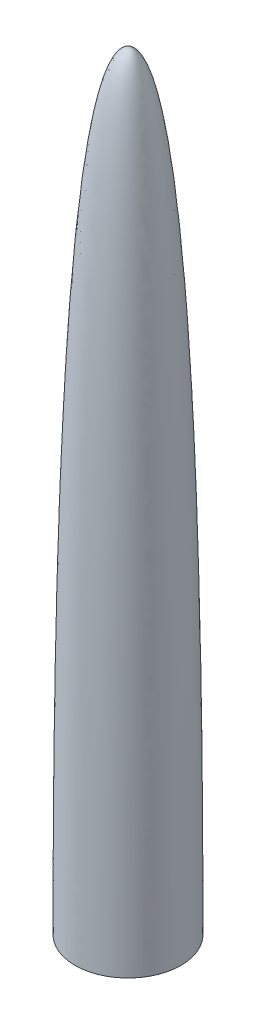
from build123d import *


with BuildPart() as part:
    # Sketch1 → Revolve1 (revolve)
    with BuildSketch(Plane.XY):
        with BuildLine():
            Line((0, 409.654213515), (0, 412.75))
            add(Edge.make_bspline(
                [(0, 412.75), (25.4, 412.75), (28.4988, 152.4), (28.4988, 0)],
                knots=[0, 0, 0, 0, 1, 1, 1, 1], degree=3))
            Line((28.4988, 0), (26.492020388, 0))
            Line((26.492020388, 0), (26.492020388, 2.0066))
            add(Edge.make_bspline(
                [(2.0066, 409.654213515), (2.149698713, 409.509236806), (2.411493219, 409.221386571), (2.987482883, 408.493454054), (3.720652511, 407.373068114), (4.617264726, 405.681670707), (5.807176946, 402.992229452), (7.264933842, 398.847767212), (8.934508891, 392.716553913), (10.515604876, 385.503405124), (12.501965167, 374.534347284), (14.756942944, 358.449413562), (17.112977898, 335.836453156), (19.140335864, 310.383994181), (20.861721564, 282.558603797), (22.300580339, 252.824154762), (23.480622222, 221.643240653), (24.425698158, 189.477715276), (25.159726589, 156.789003641), (25.706663736, 124.038262208), (26.026516367, 97.078434559), (26.212836501, 75.940480163), (26.320795213, 60.359552642), (26.399972351, 45.108810839), (26.444468814, 32.722838088), (26.468675418, 23.037013311), (26.481510324, 15.89036591), (26.48808469, 10.042159304), (26.491060195, 5.424306994), (26.491815656, 3.148604334), (26.492020388, 2.0066)],
                knots=[0.046987098, 0.046987098, 0.046987098, 0.046987098, 0.054398323, 0.061809547, 0.076631996, 0.091454445, 0.106276893, 0.135921791, 0.165566689, 0.195211586, 0.224856484, 0.284146279, 0.343436074, 0.40272587, 0.462015665, 0.52130546, 0.580595255, 0.639885051, 0.699174846, 0.758464641, 0.817754436, 0.847399334, 0.877044232, 0.906689129, 0.936334027, 0.951156476, 0.965978924, 0.980801373, 0.988212598, 0.995623822, 0.995623822, 0.995623822, 0.995623822], degree=3))
            Line((2.0066, 409.654213515), (0, 409.654213515))
        make_face()
    revolve(axis=Axis((0, 433.3875, 0), (0, -1, 0)))


solid = part.part
